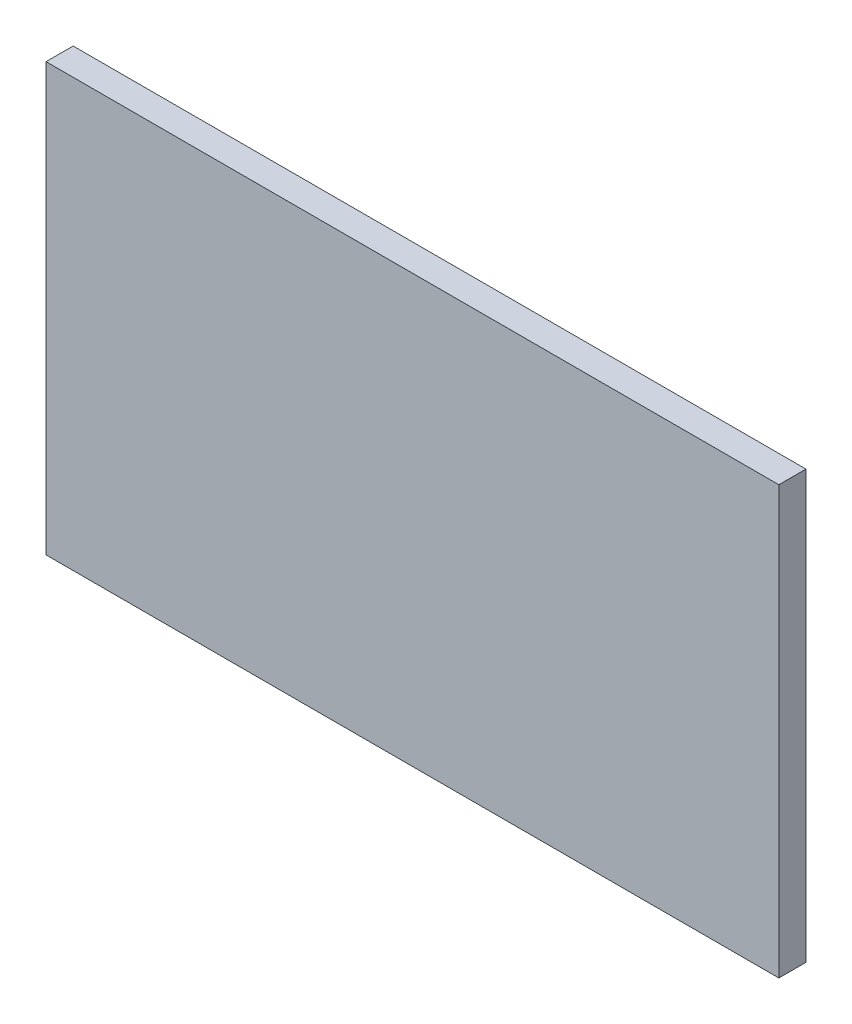
from build123d import *

# Parameters (mm, degrees)
ESQUISSE1_W        = 81.079013829
ESQUISSE1_H        = 47.265901456
BOSS_EXTRU_1_DEPTH = 3


with BuildPart() as part:
    # Esquisse1 → Boss.-Extru.1 (new body)
    with BuildSketch(Plane.XY):
        with Locations((40.539506915, -23.632950728)):
            Rectangle(ESQUISSE1_W, ESQUISSE1_H)
    extrude(amount=BOSS_EXTRU_1_DEPTH)


solid = part.part
